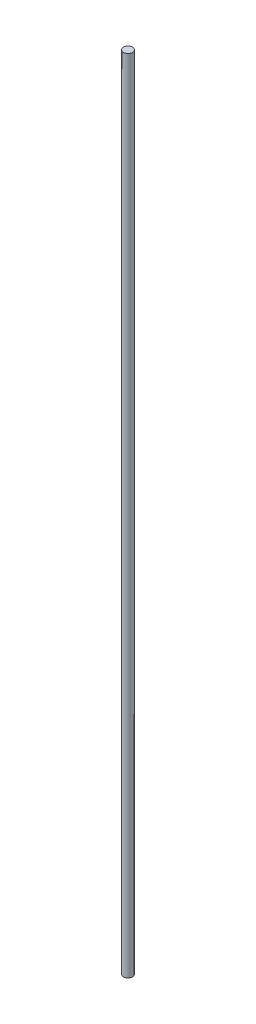
from build123d import *

# Parameters (mm, degrees)
SKETCH1_W = 4
SKETCH1_H = 700


with BuildPart() as part:
    # Sketch1 → Revolve1 (revolve)
    with BuildSketch(Plane.XY):
        with Locations((2, 350)):
            Rectangle(SKETCH1_W, SKETCH1_H)
    revolve(axis=Axis((0, 700, 0), (0, -1, 0)))


solid = part.part
